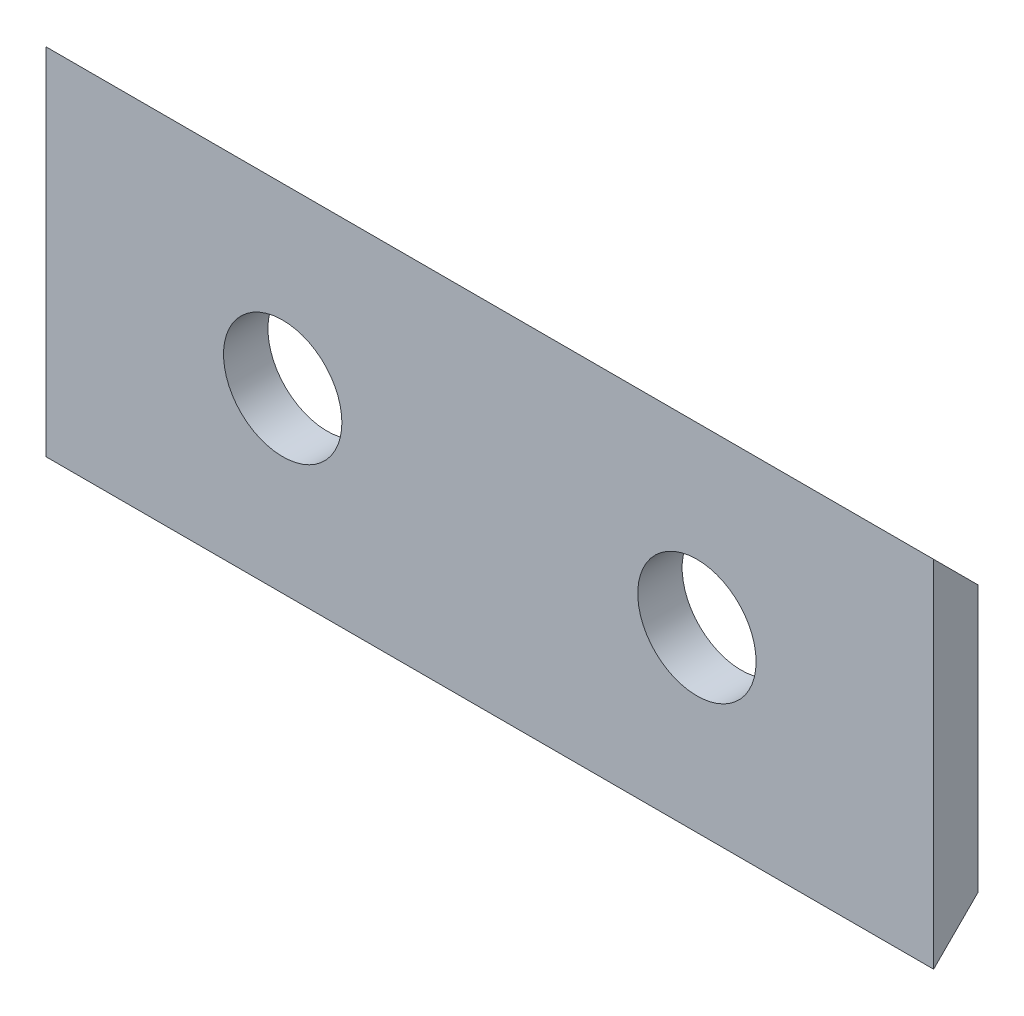
from build123d import *

# Parameters (mm, degrees)
SKETCH1_W           = 30
SKETCH1_H           = 12
SKETCH1_R           = 2
BOSS_EXTRUDE1_DEPTH = 1.5
CUT_EXTRUDE1_DEPTH  = 31


with BuildPart() as part:
    # Sketch1 → Boss-Extrude1 (new body)
    with BuildSketch(Plane.XY):
        with Locations((-15, 6)):
            Rectangle(SKETCH1_W, SKETCH1_H)
        with Locations((-22, 6)):
            Circle(SKETCH1_R, mode=Mode.SUBTRACT)
        with Locations((-8, 6)):
            Circle(SKETCH1_R, mode=Mode.SUBTRACT)
    extrude(amount=BOSS_EXTRUDE1_DEPTH)

    # Sketch2 → Cut-Extrude1 (cut, through all)
    with BuildSketch(Plane(origin=(0, 0, 0), x_dir=(0, 0, -1), z_dir=(1, 0, 0))):
        Polygon((0, 12), (-1.5, 12), (0, 10.5), align=None)
        Polygon((0, 0), (0, 1.5), (-1.5, 0), align=None)
    extrude(amount=-CUT_EXTRUDE1_DEPTH, mode=Mode.SUBTRACT)


solid = part.part
